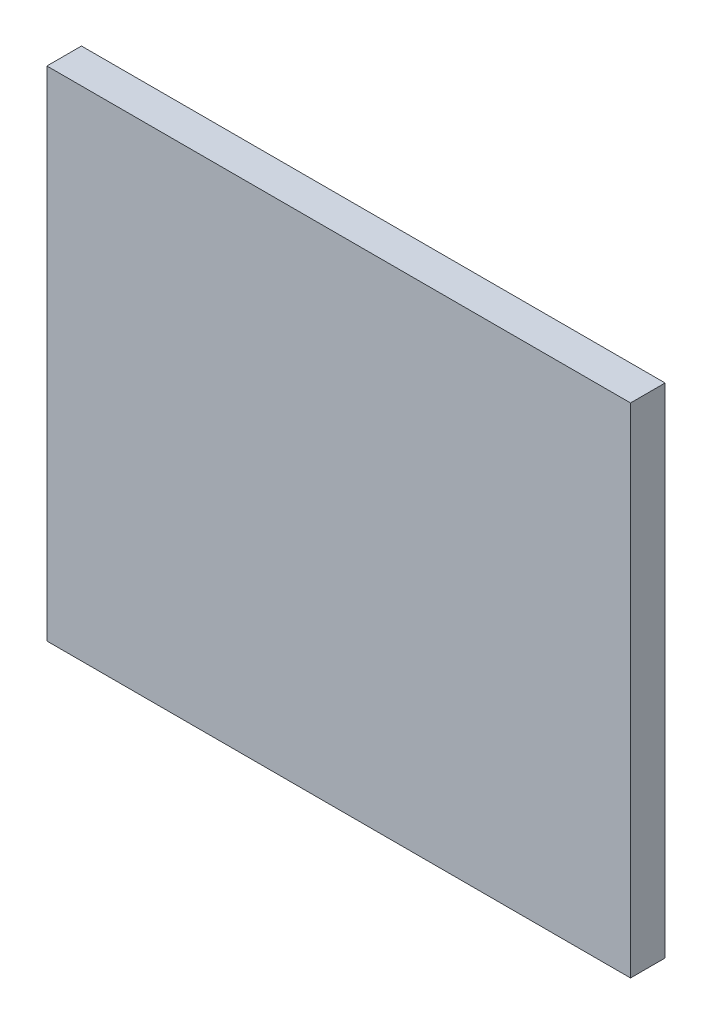
from build123d import *

# Parameters (mm, degrees)
BOSS_EXTRUDE1_START = 50
SKETCH1_W           = 135
SKETCH1_H           = 115.198794821
BOSS_EXTRUDE1_DEPTH = 8


with BuildPart() as part:
    # Sketch1 → Boss-Extrude1 (new body)
    with BuildSketch(Plane.XY.offset(BOSS_EXTRUDE1_START)):
        with Locations((0, 37.599397411)):
            Rectangle(SKETCH1_W, SKETCH1_H)
    extrude(amount=BOSS_EXTRUDE1_DEPTH)


solid = part.part
